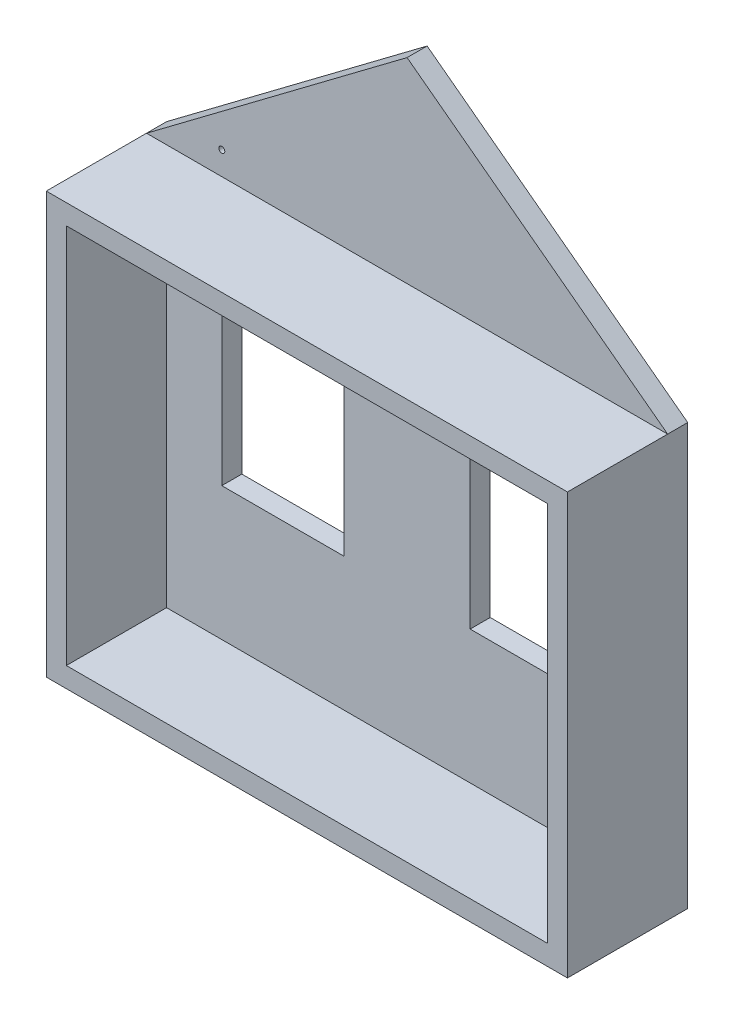
from build123d import *

# Parameters (mm, degrees)
SKETCH_2_W          = 2600
SKETCH_2_H          = 2100
SKETCH_2_W_2        = 2400
SKETCH_2_H_2        = 1900
EXTRUDE_1_DEPTH     = 500
SKETCH_3_R          = 15
SKETCH_3_W          = 609.782472484
SKETCH_3_H          = 916.628139727
EXTRUDE_1_2_DEPTH   = 100
CUT_EXTRUDE_1_DEPTH = 70


with BuildPart() as part:
    # Эскиз2 → Extrude 1 (new body)
    with BuildSketch(Plane.XY):
        with Locations((1250, 1000)):
            Rectangle(SKETCH_2_W, SKETCH_2_H)
        with Locations((1250, 1000)):
            Rectangle(SKETCH_2_W_2, SKETCH_2_H_2, mode=Mode.SUBTRACT)
    extrude(amount=EXTRUDE_1_DEPTH)

    # Эскиз3 → Extrude 1 2 (add)
    with BuildSketch(Plane(origin=(0, 0, 0), x_dir=(-1, 0, 0), z_dir=(0, 0, -1))):
        Polygon((-2550, 2050), (-2550, -50), (50, -50), (50, 2050), (-1250, 3026.785782271), align=None)
        with Locations((-325.534447993, 2166.166351537)):
            Circle(SKETCH_3_R, mode=Mode.SUBTRACT)
        with Locations((-630.425684235, 1173.270435634)):
            Rectangle(SKETCH_3_W, SKETCH_3_H, mode=Mode.SUBTRACT)
        with Locations((-1869.574315765, 1173.270435634)):
            Rectangle(SKETCH_3_W, SKETCH_3_H, mode=Mode.SUBTRACT)
    extrude(amount=EXTRUDE_1_2_DEPTH)

    # Эскиз4 → Вырез-Вытянуть1 (cut)
    with BuildSketch(Plane(origin=(0, 0, -100), x_dir=(-1, 0, 0), z_dir=(0, 0, -1))):
        Polygon((-2379.000274161, 2086.775717822), (-1259.958745803, 2935.636818267), (-89.207637204, 2086.775717822), align=None)
    extrude(amount=-CUT_EXTRUDE_1_DEPTH, mode=Mode.SUBTRACT)


solid = part.part
